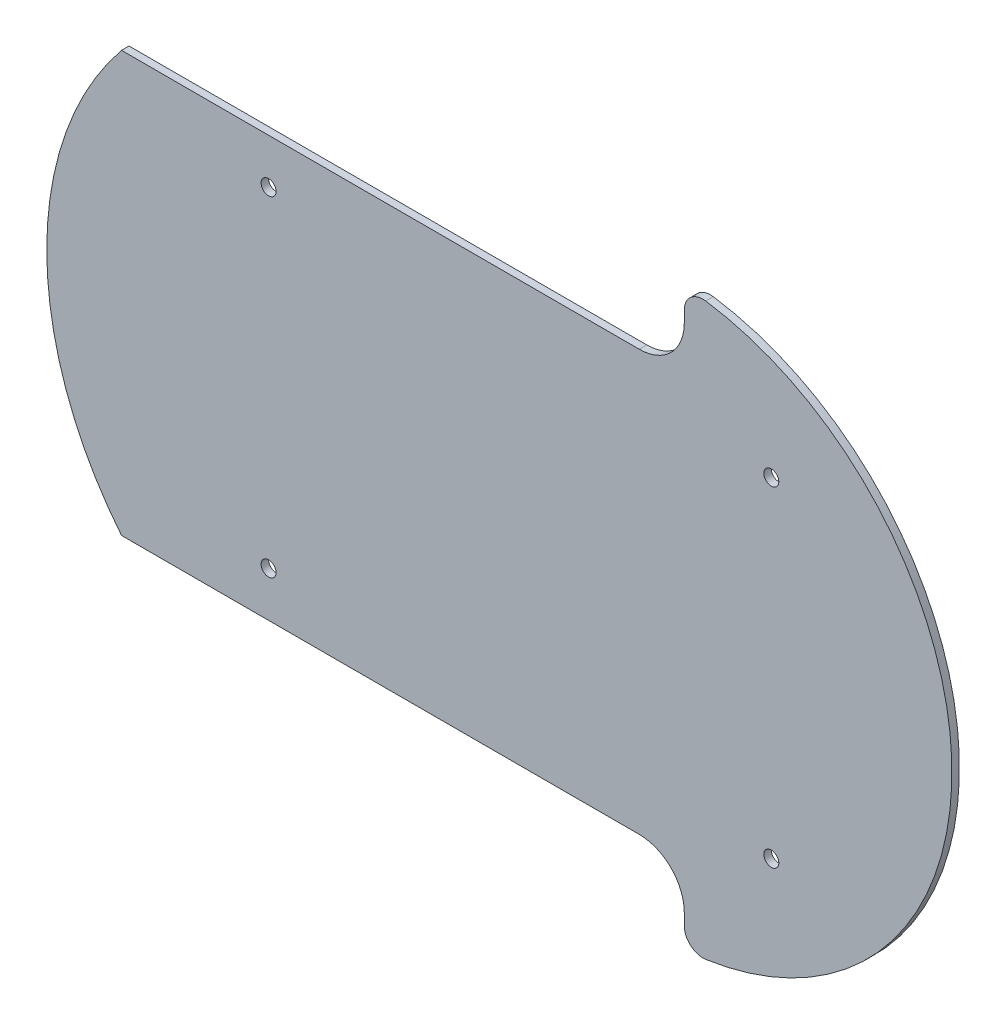
from build123d import *

# Parameters (mm, degrees)
SKETCH1_R           = 2
BOSS_EXTRUDE1_DEPTH = 2


with BuildPart() as part:
    # Sketch1 → Boss-Extrude1 (new body)
    with BuildSketch(Plane.XY):
        with BuildLine():
            Line((43.801010204, 68), (43.801010204, 71.053350769))
            ThreePointArc((43.801010204, 71.053350769), (45.533161176, 74.837681982), (49.529475295, 76))
            ThreePointArc((49.529475295, 76), (115.157062367, 0), (49.529475295, -76))
            ThreePointArc((49.529475295, -76), (45.533161176, -74.837681982), (43.801010204, -71.053350769))
            Line((43.801010204, -71.053350769), (43.801010204, -68))
            ThreePointArc((43.801010204, -68), (40.286291578, -59.514718626), (31.801010204, -56))
            Line((31.801010204, -56), (-106.198989796, -56))
            ThreePointArc((-106.198989796, -56), (-126.131547425, 0), (-106.198989796, 56))
            Line((-106.198989796, 56), (31.801010204, 56))
            ThreePointArc((31.801010204, 56), (40.286291578, 59.514718626), (43.801010204, 68))
        make_face()
        with Locations((67, 44)):
            Circle(SKETCH1_R, mode=Mode.SUBTRACT)
        with Locations((67, -44)):
            Circle(SKETCH1_R, mode=Mode.SUBTRACT)
        with Locations((-67, 44)):
            Circle(SKETCH1_R, mode=Mode.SUBTRACT)
        with Locations((-67, -44)):
            Circle(SKETCH1_R, mode=Mode.SUBTRACT)
    extrude(amount=BOSS_EXTRUDE1_DEPTH)


solid = part.part
